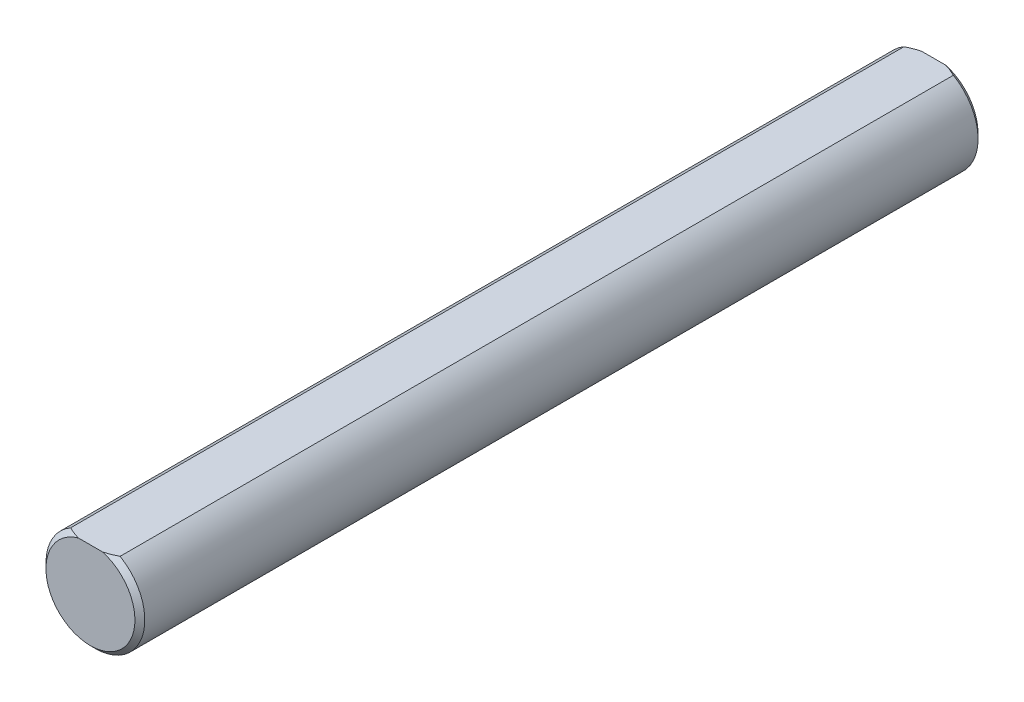
from build123d import *

# Parameters (mm, degrees)
SKETCH3_R                = 3.175
BOSS_EXTRUDE2_DEPTH      = 27.08
BOSS_EXTRUDE2_DEPTH_BACK = 27.08
CUT_EXTRUDE5_DEPTH       = 28.08
CUT_EXTRUDE5_DEPTH_BACK  = 28.08
CHAMFER1_SIZE            = 0.3175


with BuildPart() as part:
    # Sketch3 → Boss-Extrude2 (new body, two sides)
    with BuildSketch(Plane.XY) as boss_extrude2_sk:
        Circle(SKETCH3_R)
    extrude(amount=BOSS_EXTRUDE2_DEPTH)
    extrude(boss_extrude2_sk.sketch, amount=-BOSS_EXTRUDE2_DEPTH_BACK)

    # Sketch10 → Cut-Extrude5 (cut, two sides)
    with BuildSketch(Plane.XY) as cut_extrude5_sk:
        with BuildLine():
            Line((-1.5875, 2.749630657), (1.5875, 2.749630657))
            ThreePointArc((1.5875, 2.749630657), (0, 3.175), (-1.5875, 2.749630657))
        make_face()
    extrude(amount=CUT_EXTRUDE5_DEPTH, mode=Mode.SUBTRACT)
    extrude(cut_extrude5_sk.sketch, amount=-CUT_EXTRUDE5_DEPTH_BACK, mode=Mode.SUBTRACT)

    # Chamfer1
    chamfer1_edges = [part.edges().sort_by_distance(p)[0] for p in [
        (0, -3.175, -27.08),
        (0, -3.175, 27.08),
    ]]
    chamfer(chamfer1_edges, length=CHAMFER1_SIZE)


solid = part.part
